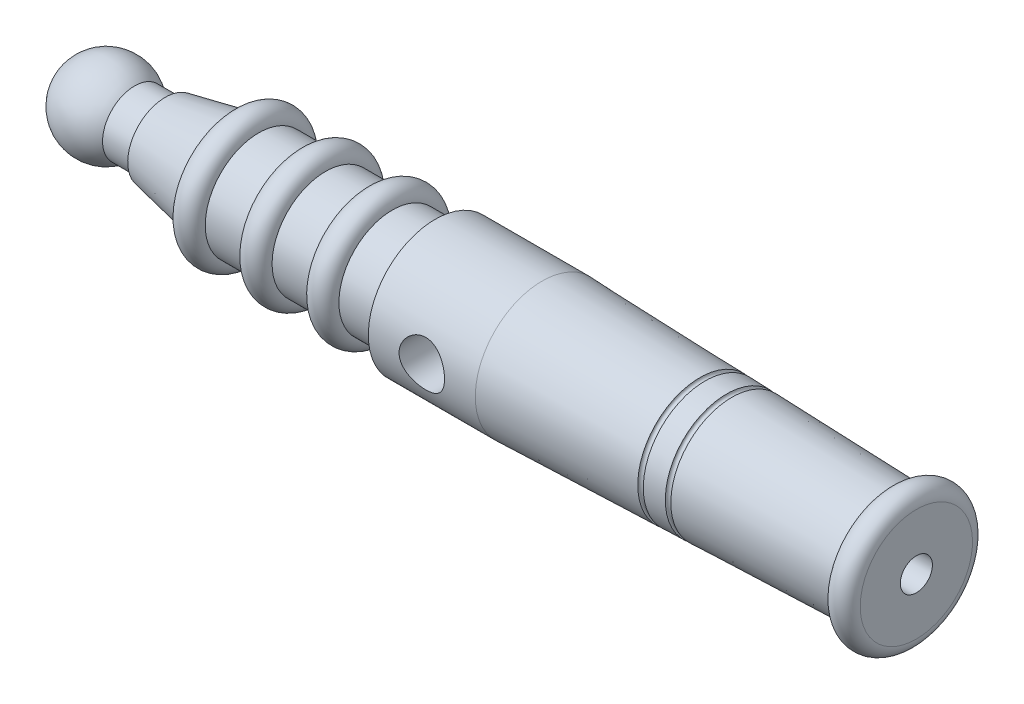
from build123d import *

# Parameters (mm, degrees)
SZKIC3_R                        = 4.25
WYTNIJ_WYCI_GNI_CIE1_DEPTH      = 14.000000102
WYTNIJ_WYCI_GNI_CIE1_DEPTH_BACK = 14.000000102


with BuildPart() as part:
    # Szkic2 → Obrót1 (revolve)
    with BuildSketch(Plane.XY):
        with BuildLine():
            Line((0, 0), (109.499999992, 0))
            Line((109.499999992, 0), (109.499999992, 3))
            Line((109.499999992, 3), (159.499999992, 3))
            Line((159.499999992, 3), (159.499999992, 10.500000002))
            ThreePointArc((159.499999992, 10.500000002), (157.000100149, 13), (154.5, 10.500200316))
            Line((154.5, 10.500200316), (124.983210551, 11.408318258))
            ThreePointArc((124.983210551, 11.408318258), (124.468071222, 10.923930528), (123.983683493, 11.439069856))
            Line((123.983683493, 11.439069856), (119.985575262, 11.56207625))
            ThreePointArc((119.985575262, 11.56207625), (119.470435934, 11.07768852), (118.986048204, 11.592827848))
            Line((118.986048204, 11.592827848), (89.5, 12.5))
            Line((89.5, 12.5), (69.5, 12.5))
            Line((69.5, 12.5), (69.5, 10))
            Line((69.5, 10), (61.5, 10))
            ThreePointArc((61.5, 10), (59, 12.5), (56.5, 10))
            Line((56.5, 10), (49, 10))
            ThreePointArc((49, 10), (46.5, 12.5), (44, 10))
            Line((44, 10), (36.5, 10))
            ThreePointArc((36.5, 10), (33.753655955, 12.487833317), (31.548548311, 9.509709662))
            Line((31.548548311, 9.509709662), (19, 7))
            Line((19, 7), (19, 6))
            Line((19, 6), (13.291502622, 6))
            ThreePointArc((13.291502622, 6), (4.708497378, 7.291502622), (0, 0))
        make_face()
    revolve(axis=Axis((0, 0, 0), (1, 0, 0)))

    # Szkic3 → Wytnij-wyciągnięcie1 (cut, two sides)
    with BuildSketch(Plane.XY) as wytnij_wyci_gni_cie1_sk:
        with Locations((79.5, 0)):
            Circle(SZKIC3_R)
    extrude(amount=WYTNIJ_WYCI_GNI_CIE1_DEPTH, mode=Mode.SUBTRACT)
    extrude(wytnij_wyci_gni_cie1_sk.sketch, amount=-WYTNIJ_WYCI_GNI_CIE1_DEPTH_BACK, mode=Mode.SUBTRACT)


solid = part.part
